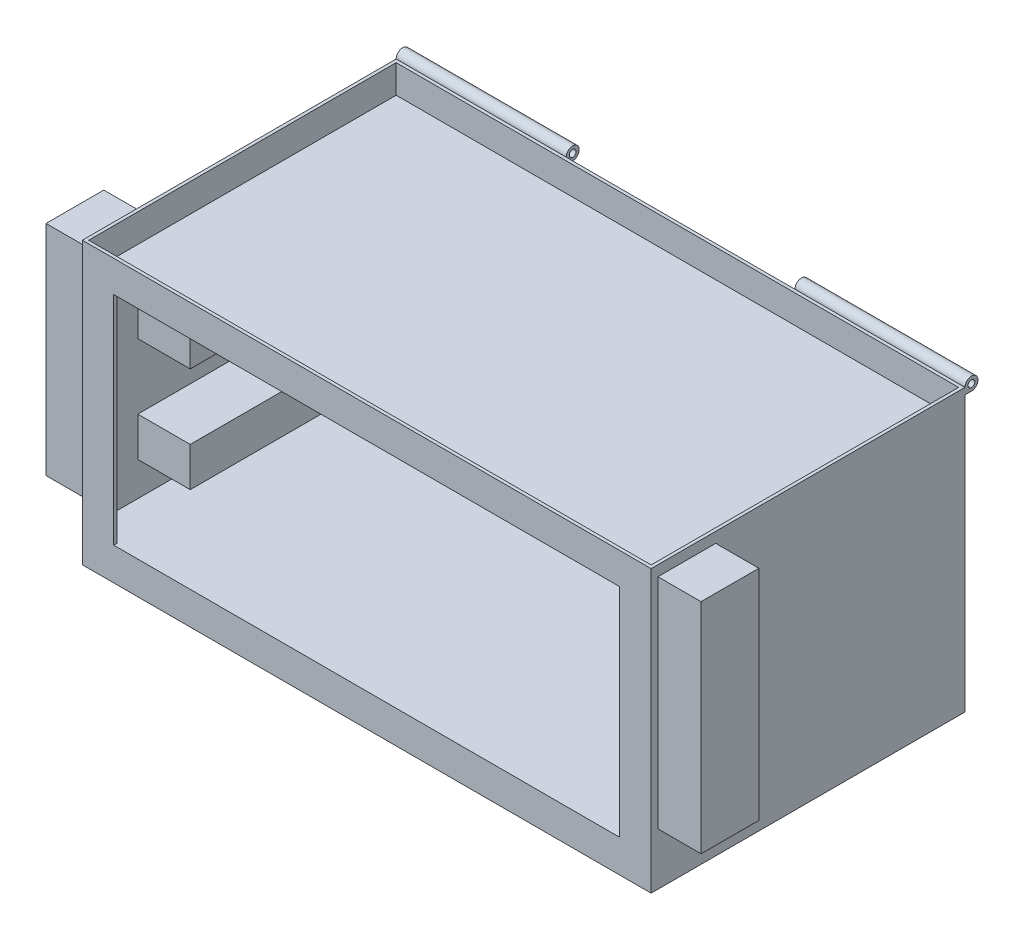
from build123d import *

# Parameters (mm, degrees)
SKETCH1_W                           = 276.225
SKETCH1_H                           = 152.4
BULK_EXTRUDE_DEPTH                  = 136.525
SKETCH1_13_W                        = 273.177
SKETCH1_13_H                        = 149.352
SKETCH1_13_W_2                      = 245.745
SKETCH1_13_H_2                      = 1.524
INNER_SHELL_CUT_DEPTH               = 120.65
SKETCH1_14_W                        = 245.745
SKETCH1_14_H                        = 1.524
TOP_WALL_EXTRUDE_DEPTH              = 15.24
TOP_START                           = -15.24
SKETCH1_15_W                        = 273.177
SKETCH1_15_H                        = 149.352
TOP_FLOOR_EXTRUDE_DEPTH             = 1.524
SKETCH5_R                           = 1.651
HINGE_EXTRUDE_DEPTH                 = 82.55
SKETCH7_W                           = 25.4635
SKETCH7_H                           = 19.05
RAILS_EXTRUDE_DEPTH                 = 125.476
SKETCH9_W                           = 28.067
SKETCH9_H                           = 106.045
LATCH_CLEAR_BOX_RIGHT_EXTRUDE_DEPTH = 20.955


with BuildPart() as part:
    # Sketch1 → Bulk-Extrude (new body)
    with BuildSketch(Plane(origin=(0, 0, 0), x_dir=(1, 0, 0), z_dir=(0, 1, 0))):
        with Locations((136.5885, 74.676)):
            Rectangle(SKETCH1_W, SKETCH1_H)
    extrude(amount=-BULK_EXTRUDE_DEPTH)

    # Sketch1_13 → Inner Shell-Cut (cut)
    with BuildSketch(Plane(origin=(0, 0, 0), x_dir=(1, 0, 0), z_dir=(0, 1, 0))):
        with Locations((136.5885, 74.676)):
            Rectangle(SKETCH1_13_W, SKETCH1_13_H)
        with Locations((136.5885, -0.762)):
            Rectangle(SKETCH1_13_W_2, SKETCH1_13_H_2)
    extrude(amount=-INNER_SHELL_CUT_DEPTH, mode=Mode.SUBTRACT)

    # Sketch1_14 → Top Wall-Extrude (add)
    with BuildSketch(Plane(origin=(0, 0, 0), x_dir=(1, 0, 0), z_dir=(0, 1, 0))):
        with Locations((136.5885, -0.762)):
            Rectangle(SKETCH1_14_W, SKETCH1_14_H)
    extrude(amount=-TOP_WALL_EXTRUDE_DEPTH)

    # Sketch1_15 → Top Floor-Extrude (add)
    with BuildSketch(Plane(origin=(0, 0, 0), x_dir=(1, 0, 0), z_dir=(0, 1, 0)).offset(TOP_START)):
        with Locations((136.5885, 74.676)):
            Rectangle(SKETCH1_15_W, SKETCH1_15_H)
    extrude(amount=TOP_FLOOR_EXTRUDE_DEPTH)

    # Sketch5 → Hinge-Extrude (add)
    with BuildSketch(Plane(origin=(274.701, 0, 0), x_dir=(0, 0, -1), z_dir=(1, 0, 0))):
        with BuildLine():
            Line((150.876, 0), (150.876, -3.175))
            Line((150.876, -3.175), (154.051, -3.175))
            ThreePointArc((154.051, -3.175), (156.29606403, 2.24506403), (150.876, 0))
        make_face()
        with Locations((154.051, 0)):
            Circle(SKETCH5_R, mode=Mode.SUBTRACT)
    hinge_extrude = extrude(amount=-HINGE_EXTRUDE_DEPTH)

    # Mirror1: Hinge-Extrude across plane
    add(hinge_extrude.mirror(Plane(origin=(136.5885, 0, 0), x_dir=(0, 0, 1), z_dir=(1, 0, 0))))

    # Sketch7 → Rails-Extrude (add)
    with BuildSketch(Plane.XY.offset(-149.352)):
        with Locations((12.73175, -43.815)):
            Rectangle(SKETCH7_W, SKETCH7_H)
        with Locations((260.44525, -43.815)):
            Rectangle(SKETCH7_W, SKETCH7_H)
        with Locations((12.73175, -94.615)):
            Rectangle(SKETCH7_W, SKETCH7_H)
        with Locations((260.44525, -94.615)):
            Rectangle(SKETCH7_W, SKETCH7_H)
    extrude(amount=RAILS_EXTRUDE_DEPTH)


with BuildPart() as body_2:
    # Sketch9 → Latch Clear. Box_ Right-Extrude (new body)
    with BuildSketch(Plane(origin=(274.701, 0, 0), x_dir=(0, 0, -1), z_dir=(1, 0, 0))):
        with Locations((15.8115, -58.1025)):
            Rectangle(SKETCH9_W, SKETCH9_H)
    latch_clear_box_right_extrude = extrude(amount=LATCH_CLEAR_BOX_RIGHT_EXTRUDE_DEPTH)


with BuildPart() as part_1:
    add(part.part)

    # Latch Clear. Box_ Left-Mirror: Latch Clear. Box_ Right-Extrude across plane
    add(latch_clear_box_right_extrude.mirror(Plane(origin=(136.5885, 0, 0), x_dir=(0, 0, 1), z_dir=(1, 0, 0))))


solid = Compound([body_2.part, part_1.part])
